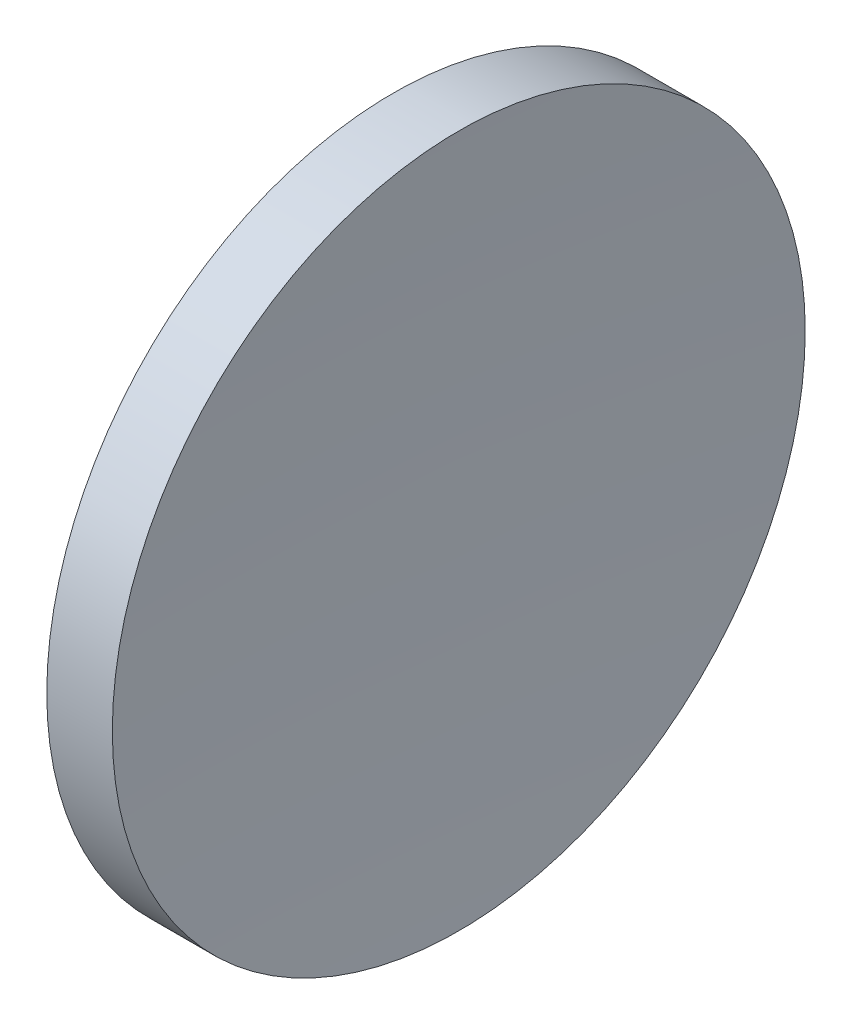
from build123d import *


with BuildPart() as part:
    # 草图1 → 旋转1 (revolve)
    with BuildSketch(Plane.XY, mode=Mode.PRIVATE) as revolve_1_sk:
        with BuildLine():
            Line((57.532337053, 32.610768129), (57.532337053, 45.110768129))
            Line((57.532337053, 45.110768129), (59.8975341, 45.110768129))
            ThreePointArc((59.8975341, 45.110768129), (59.620107425, 38.863538606), (59.532337053, 32.610768129))
            Line((59.532337053, 32.610768129), (57.532337053, 32.610768129))
        make_face()
    revolve(revolve_1_sk.sketch.rotate(Axis((56.10091508, 32.610768129, 0), (1, 0, 0)), 90), axis=Axis((56.10091508, 32.610768129, 0), (1, 0, 0)))  # turned: the seam where the file's is


solid = part.part
